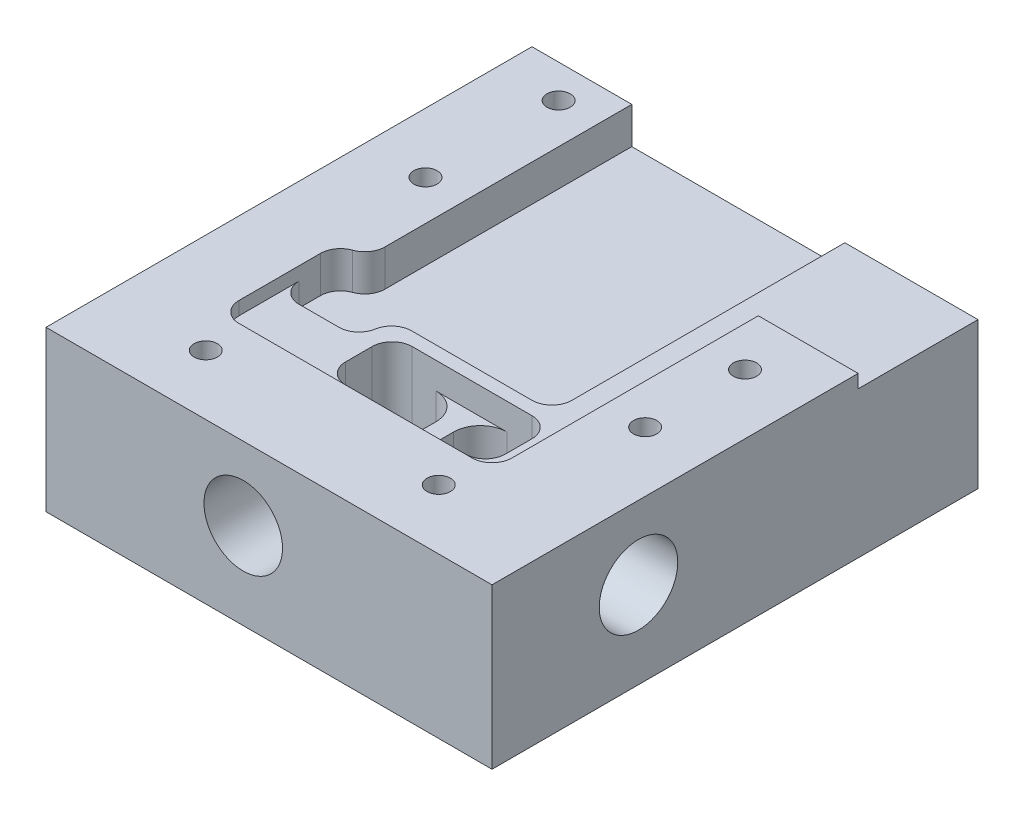
from build123d import *

# Parameters (mm, degrees)
SKETCH1_W                = 67
SKETCH1_H                = 73
BOSS_EXTRUDE1_DEPTH      = 15
BOSS_EXTRUDE2_DEPTH      = 3.5
SKETCH6_W                = 24
SKETCH6_H                = 10
CUT_EXTRUDE2_DEPTH       = 16
SKETCH11_W               = 67
SKETCH11_H               = 73
BOSS_EXTRUDE4_DEPTH      = 3.5
SKETCH13_W               = 15
SKETCH13_H               = 40
BOSS_EXTRUDE6_DEPTH      = 5.5
SKETCH14_R               = 1.75
CUT_EXTRUDE7_DEPTH       = 10
BOSS_EXTRUDE7_DEPTH      = 5.5
FILLET5_R                = 3
SKETCH20_W               = 15
SKETCH20_H               = 18
BOSS_EXTRUDE8_DEPTH      = 3.5
FILLET10_R               = 3
FILLET11_R               = 3
FILLET12_R               = 3
FILLET13_R               = 3
SKETCH21_W               = 2.649172372
SKETCH21_H               = 10
BOSS_EXTRUDE9_DEPTH      = 12
FILLET15_R               = 4
SKETCH19_R               = 1.75
CUT_EXTRUDE11_DEPTH      = 10
SKETCH23_R               = 4
CUT_EXTRUDE12_DEPTH      = 2
CUT_EXTRUDE12_DEPTH_BACK = 91.278735196
SKETCH24_R               = 5.9
CUT_EXTRUDE13_DEPTH      = 10
SKETCH25_R               = 4
CUT_EXTRUDE14_DEPTH      = 2
CUT_EXTRUDE14_DEPTH_BACK = 90.695317764
SKETCH26_R               = 5.9
CUT_EXTRUDE15_DEPTH      = 10


with BuildPart() as part:
    # Sketch1 → Boss-Extrude1 (new body)
    with BuildSketch(Plane(origin=(0, 0, 0), x_dir=(1, 0, 0), z_dir=(0, 1, 0))):
        with Locations((33.5, 36.5)):
            Rectangle(SKETCH1_W, SKETCH1_H)
    extrude(amount=BOSS_EXTRUDE1_DEPTH)

    # Sketch5 → Boss-Extrude2 (add)
    with BuildSketch(Plane(origin=(0, 15, 0), x_dir=(1, 0, 0), z_dir=(0, 1, 0))):
        with BuildLine():
            Line((18.5, 15), (11, 15))
            Line((11, 15), (11, 24))
            Line((11, 24), (14.788897449, 24))
            Line((14.788897449, 24), (20, 24))
            ThreePointArc((20, 24), (22.121320344, 24.878679656), (23, 27))
            Line((23, 27), (23, 29))
            Line((23, 29), (47, 29))
            Line((47, 29), (47, 73))
            Line((47, 73), (52, 73))
            Line((52, 73), (52, 15))
            Line((52, 15), (32, 15))
            Line((32, 15), (18.5, 15))
        make_face()
    extrude(amount=BOSS_EXTRUDE2_DEPTH)

    # Sketch6 → Cut-Extrude2 (cut)
    with BuildSketch(Plane(origin=(0, 18.5, 0), x_dir=(1, 0, 0), z_dir=(0, 1, 0))):
        with Locations((37, 22)):
            Rectangle(SKETCH6_W, SKETCH6_H)
    extrude(amount=-CUT_EXTRUDE2_DEPTH, mode=Mode.SUBTRACT)

    # Sketch11 → Boss-Extrude4 (add)
    with BuildSketch(Plane.XZ):
        with Locations((33.5, -36.5)):
            Rectangle(SKETCH11_W, SKETCH11_H)
    extrude(amount=BOSS_EXTRUDE4_DEPTH)

    # Sketch13 → Boss-Extrude6 (add)
    with BuildSketch(Plane(origin=(0, 15, 0), x_dir=(1, 0, 0), z_dir=(0, 1, 0))):
        with Locations((59.5, 35)):
            Rectangle(SKETCH13_W, SKETCH13_H)
    extrude(amount=BOSS_EXTRUDE6_DEPTH)

    # Sketch14 → Cut-Extrude7 (cut)
    with BuildSketch(Plane(origin=(0, 20.5, 0), x_dir=(1, 0, 0), z_dir=(0, 1, 0))):
        with Locations(Location((58, 47, 0), (0, 0, 270))):
            Circle(SKETCH14_R)
        with Locations(Location((58, 32, 0), (0, 0, 270))):
            Circle(SKETCH14_R)
    extrude(amount=-CUT_EXTRUDE7_DEPTH, mode=Mode.SUBTRACT)

    # Sketch18 → Boss-Extrude7 (add)
    with BuildSketch(Plane(origin=(0, 15, 0), x_dir=(1, 0, 0), z_dir=(0, 1, 0))):
        with BuildLine():
            Line((15, 33.237791503), (15, 73))
            Line((15, 73), (0, 73))
            Line((0, 73), (0, 15))
            Line((0, 15), (0, 0))
            Line((0, 0), (67, 0))
            Line((67, 0), (67, 15))
            Line((67, 15), (15, 15))
            Line((15, 15), (13.782507359, 15))
            ThreePointArc((13.782507359, 15), (11.803129735, 15.9491273), (11, 17.992105772))
            Line((11, 17.992105772), (11, 30.237791503))
            ThreePointArc((11, 30.237791503), (11.878679656, 32.359111846), (14, 33.237791503))
            Line((14, 33.237791503), (15, 33.237791503))
        make_face()
    extrude(amount=BOSS_EXTRUDE7_DEPTH)

    # Fillet5
    fillet5_edges = [part.edges().sort_by_distance(p)[0] for p in [
        (52, 19.5, -15),
    ]]
    fillet(fillet5_edges, radius=FILLET5_R)

    # Sketch20 → Boss-Extrude8 (add)
    with BuildSketch(Plane(origin=(0, 15, 0), x_dir=(1, 0, 0), z_dir=(0, 1, 0))):
        with Locations((59.5, 64)):
            Rectangle(SKETCH20_W, SKETCH20_H)
    extrude(amount=BOSS_EXTRUDE8_DEPTH)

    # Fillet10
    fillet10_edges = [part.edges().sort_by_distance(p)[0] for p in [
        (47, 16.75, -29),
    ]]
    fillet(fillet10_edges, radius=FILLET10_R)

    # Fillet11
    fillet11_edges = [part.edges().sort_by_distance(p)[0] for p in [
        (23, 16.75, -29),
        (11, 16.75, -24),
    ]]
    fillet(fillet11_edges, radius=FILLET11_R)

    # Fillet12
    fillet12_edges = [part.edges().sort_by_distance(p)[0] for p in [
        (15, 17.75, -33.237791503),
    ]]
    fillet(fillet12_edges, radius=FILLET12_R)

    # Fillet13
    fillet13_edges = [part.edges().sort_by_distance(p)[0] for p in [
        (25, 10.5, -17),
        (25, 10.5, -27),
        (49, 10.5, -27),
        (49, 10.5, -17),
    ]]
    fillet(fillet13_edges, radius=FILLET13_R)

    # Sketch21 → Boss-Extrude9 (add)
    with BuildSketch(Plane(origin=(0, 2.5, 0), x_dir=(1, 0, 0), z_dir=(0, 1, 0))):
        with Locations((36.905299385, 22)):
            Rectangle(SKETCH21_W, SKETCH21_H)
    extrude(amount=BOSS_EXTRUDE9_DEPTH)

    # Fillet15
    fillet15_edges = [part.edges().sort_by_distance(p)[0] for p in [
        (35.580713199, 8.5, -27),
        (35.580713199, 8.5, -17),
        (38.229885571, 8.5, -17),
        (38.229885571, 8.5, -27),
    ]]
    fillet(fillet15_edges, radius=FILLET15_R)

    # Sketch19 → Cut-Extrude11 (cut)
    with BuildSketch(Plane(origin=(0, 20.5, 0), x_dir=(1, 0, 0), z_dir=(0, 1, 0))):
        with Locations(Location((9, 48, 0), (0, 0, 270))):
            Circle(SKETCH19_R)
        with Locations(Location((9, 68, 0), (0, 0, 270))):
            Circle(SKETCH19_R)
        with Locations(Location((15, 9, 0), (0, 0, 270))):
            Circle(SKETCH19_R)
        with Locations(Location((50, 9, 0), (0, 0, 270))):
            Circle(SKETCH19_R)
    extrude(amount=-CUT_EXTRUDE11_DEPTH, mode=Mode.SUBTRACT)

    # Sketch23 → Cut-Extrude12 (cut, two sides)
    with BuildSketch(Plane.ZY.offset(-49)) as cut_extrude12_sk:
        with Locations(Location((-22, 9.5, 0), (0, 0, 240))):
            Circle(SKETCH23_R)
    extrude(amount=CUT_EXTRUDE12_DEPTH, mode=Mode.SUBTRACT)
    extrude(cut_extrude12_sk.sketch, amount=-CUT_EXTRUDE12_DEPTH_BACK, mode=Mode.SUBTRACT)

    # Sketch24 → Cut-Extrude13 (cut)
    with BuildSketch(Plane(origin=(67, 0, 0), x_dir=(0, 0, -1), z_dir=(1, 0, 0))):
        with Locations((22, 9.5)):
            Circle(SKETCH24_R)
    extrude(amount=-CUT_EXTRUDE13_DEPTH, mode=Mode.SUBTRACT)

    # Sketch25 → Cut-Extrude14 (cut, two sides)
    with BuildSketch(Plane(origin=(0, 0, -17), x_dir=(-1, 0, 0), z_dir=(0, 0, -1))) as cut_extrude14_sk:
        with Locations(Location((-29.628343357, 9.5, 0), (0, 0, 240.784718546))):
            Circle(SKETCH25_R)
    extrude(amount=CUT_EXTRUDE14_DEPTH, mode=Mode.SUBTRACT)
    extrude(cut_extrude14_sk.sketch, amount=-CUT_EXTRUDE14_DEPTH_BACK, mode=Mode.SUBTRACT)

    # Sketch26 → Cut-Extrude15 (cut)
    with BuildSketch(Plane.XY):
        with Locations((29.628343357, 9.5)):
            Circle(SKETCH26_R)
    extrude(amount=-CUT_EXTRUDE15_DEPTH, mode=Mode.SUBTRACT)


solid = part.part
